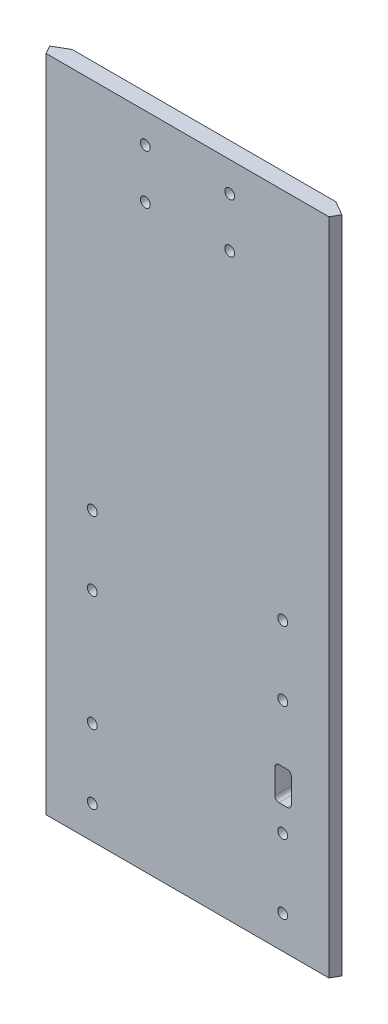
from build123d import *

# Parameters (mm, degrees)
SKETCH1_W           = 101.6
SKETCH1_H           = 254
BOSS_EXTRUDE1_DEPTH = 6.35
BOSS_EXTRUDE2_DEPTH = 254
CUT_EXTRUDE2_DEPTH  = 255
SKETCH5_R           = 1.905
CUT_EXTRUDE3_DEPTH  = 7.35
SKETCH6_R           = 1.905
CUT_EXTRUDE4_DEPTH  = 7.35
SKETCH9_W           = 6.35
SKETCH9_H           = 12.7
CUT_EXTRUDE5_DEPTH  = 7.35
FILLET1_R           = 1.5875


with BuildPart() as part:
    # Sketch1 → Boss-Extrude1 (new body)
    with BuildSketch(Plane.XY):
        with Locations((0, -25.4)):
            Rectangle(SKETCH1_W, SKETCH1_H)
    extrude(amount=BOSS_EXTRUDE1_DEPTH)

    # Sketch2 → Boss-Extrude2 (add)
    with BuildSketch(Plane(origin=(0, 101.6, 0), x_dir=(1, 0, 0), z_dir=(0, 1, 0))):
        Polygon((-50.8, 0), (-61.798522628, -6.35), (-50.8, -6.35), align=None)
        Polygon((61.798522628, -6.35), (50.8, -6.35), (50.8, 0), align=None)
    extrude(amount=-BOSS_EXTRUDE2_DEPTH)

    # Sketch4 → Cut-Extrude2 (cut, through all)
    with BuildSketch(Plane(origin=(0, 101.6, 0), x_dir=(1, 0, 0), z_dir=(0, 1, 0))):
        Polygon((56.299261314, -3.175), (54.466174209, -6.35), (61.798522628, -6.35), align=None)
        Polygon((-61.798522628, -6.35), (-54.466174209, -6.35), (-56.299261314, -3.175), align=None)
    extrude(amount=-CUT_EXTRUDE2_DEPTH, mode=Mode.SUBTRACT)

    # Sketch5 → Cut-Extrude3 (cut, through all)
    with BuildSketch(Plane.XY.offset(6.35)):
        with Locations((-36.686174209, -41.91)):
            Circle(SKETCH5_R)
        with Locations((36.686174209, -41.91)):
            Circle(SKETCH5_R)
        with Locations((36.686174209, -68.58)):
            Circle(SKETCH5_R)
        with Locations((36.686174209, -113.03)):
            Circle(SKETCH5_R)
        with Locations((36.686174209, -139.7)):
            Circle(SKETCH5_R)
        with Locations((-36.686174209, -139.7)):
            Circle(SKETCH5_R)
        with Locations((-36.686174209, -113.03)):
            Circle(SKETCH5_R)
        with Locations((-36.686174209, -68.58)):
            Circle(SKETCH5_R)
    extrude(amount=-CUT_EXTRUDE3_DEPTH, mode=Mode.SUBTRACT)

    # Sketch6 → Cut-Extrude4 (cut, through all)
    with BuildSketch(Plane.XY.offset(6.35)):
        with Locations((-16.256, 90.17)):
            Circle(SKETCH6_R)
        with Locations((16.256, 90.17)):
            Circle(SKETCH6_R)
        with Locations((16.256, 71.12)):
            Circle(SKETCH6_R)
        with Locations((-16.256, 71.12)):
            Circle(SKETCH6_R)
    extrude(amount=-CUT_EXTRUDE4_DEPTH, mode=Mode.SUBTRACT)

    # Sketch9 → Cut-Extrude5 (cut, through all)
    with BuildSketch(Plane.XY.offset(6.35)):
        with Locations((36.813174209, -97.155)):
            Rectangle(SKETCH9_W, SKETCH9_H)
    extrude(amount=-CUT_EXTRUDE5_DEPTH, mode=Mode.SUBTRACT)

    # Fillet1
    fillet1_edges = [part.edges().sort_by_distance(p)[0] for p in [
        (33.638174209, -90.805, 3.175),
        (39.988174209, -90.805, 3.175),
        (39.988174209, -103.505, 3.175),
        (33.638174209, -103.505, 3.175),
    ]]
    fillet(fillet1_edges, radius=FILLET1_R)


solid = part.part
